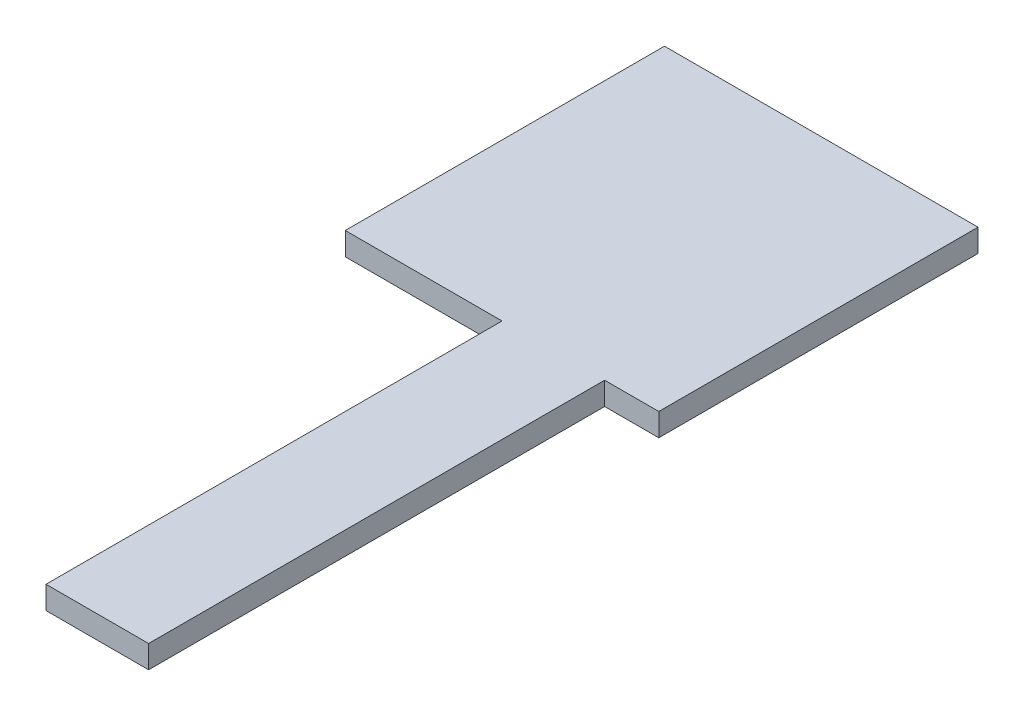
from build123d import *

# Parameters (mm, degrees)
SKETCH1_W           = 27.5
SKETCH1_H           = 28
BOSS_EXTRUDE1_DEPTH = 2
SKETCH2_W           = 9
SKETCH2_H           = 2
BOSS_EXTRUDE2_DEPTH = 40


with BuildPart() as part:
    # Sketch1 → Boss-Extrude1 (new body)
    with BuildSketch(Plane(origin=(0, 0, 0), x_dir=(1, 0, 0), z_dir=(0, 1, 0))):
        Rectangle(SKETCH1_W, SKETCH1_H)
    extrude(amount=BOSS_EXTRUDE1_DEPTH)

    # Sketch2 → Boss-Extrude2 (add)
    with BuildSketch(Plane.XY.offset(14)):
        with Locations((4.5, 1)):
            Rectangle(SKETCH2_W, SKETCH2_H)
    extrude(amount=BOSS_EXTRUDE2_DEPTH)


solid = part.part
